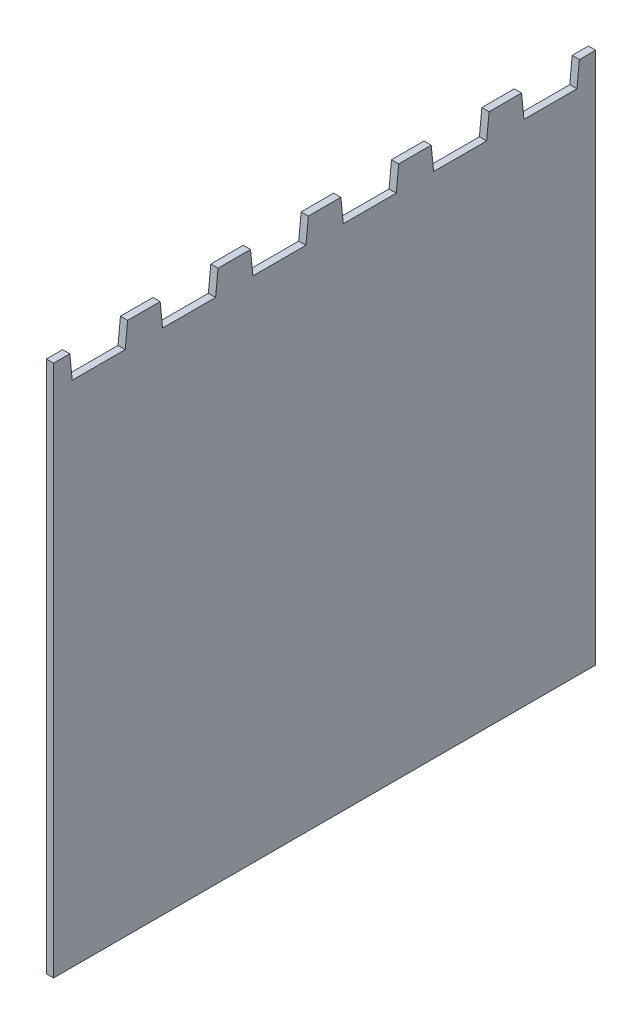
from build123d import *

# Parameters (mm, degrees)
SKETCH2_W           = 37.5
SKETCH2_H           = 206
BOSS_EXTRUDE2_DEPTH = 3
LPATTERN1_COUNT     = 6
LPATTERN1_PITCH     = 37.5


with BuildPart() as part:
    # Sketch2 → Boss-Extrude2 (new body)
    with BuildSketch(Plane(origin=(0, 0, 0), x_dir=(0, 0, -1), z_dir=(1, 0, 0))):
        Rectangle(SKETCH2_W, SKETCH2_H)
        Polygon((18.75, 118), (18.75, 103), (-18.75, 103), (-18.75, 118), (-12, 118), (-11, 108), (11, 108), (12, 118), align=None)
    boss_extrude2 = extrude(amount=BOSS_EXTRUDE2_DEPTH)

    # LPattern1: Boss-Extrude2 ×6
    with Locations(*[(0, 0, i * LPATTERN1_PITCH) for i in range(1, LPATTERN1_COUNT)]):
        add(boss_extrude2)


solid = part.part
